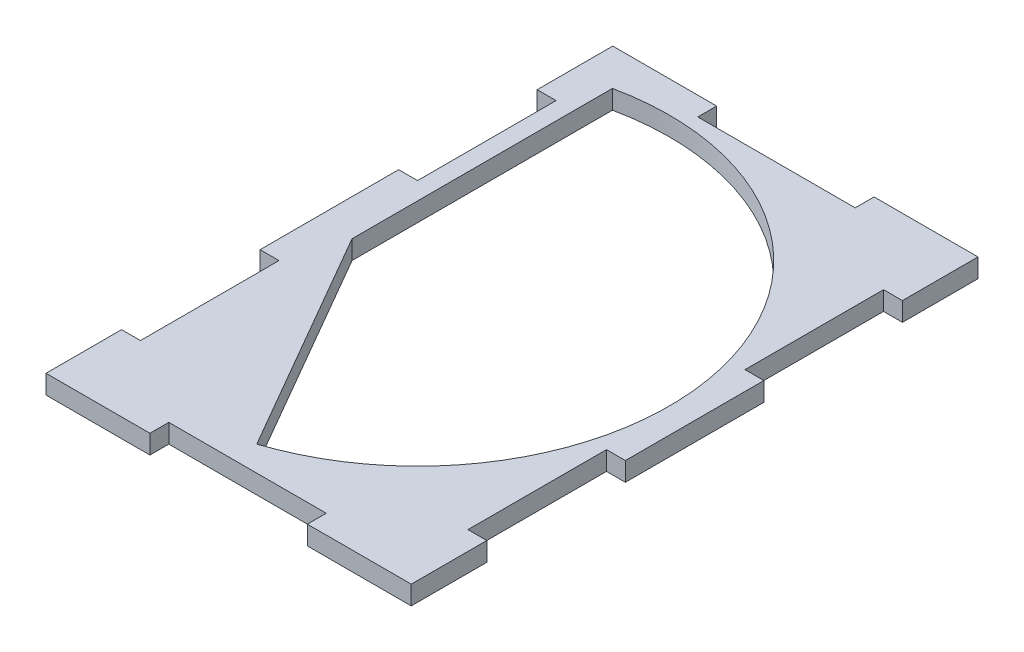
from build123d import *

# Parameters (mm, degrees)
BOSS_EXTRUDE2_DEPTH = 3


with BuildPart() as part:
    # Sketch4 → Boss-Extrude2 (new body)
    with BuildSketch(Plane(origin=(0, 0, 0), x_dir=(1, 0, 0), z_dir=(0, 1, 0))):
        Polygon((-26, -90), (-9.5, -90), (-9.5, -87), (15.5, -87), (15.5, -90), (32, -90), (32, -78), (29, -78), (29, -56), (32, -56), (32, -34), (29, -34), (29, -12), (32, -12), (32, 0), (15.5, 0), (15.5, -3), (-9.5, -3), (-9.5, 0), (-26, 0), (-26, -12), (-23, -12), (-23, -34), (-26, -34), (-26, -56), (-23, -56), (-23, -78), (-26, -78), align=None)
        with BuildLine():
            Line((-20.2, -47.197183378), (-20.2, -5.849521076))
            ThreePointArc((-20.2, -5.849521076), (26.637033052, -34.647238196), (0.473831151, -83.005309319))
            Line((0.473831151, -83.005309319), (-20.2, -47.197183378))
        make_face(mode=Mode.SUBTRACT)
    extrude(amount=BOSS_EXTRUDE2_DEPTH)


solid = part.part
